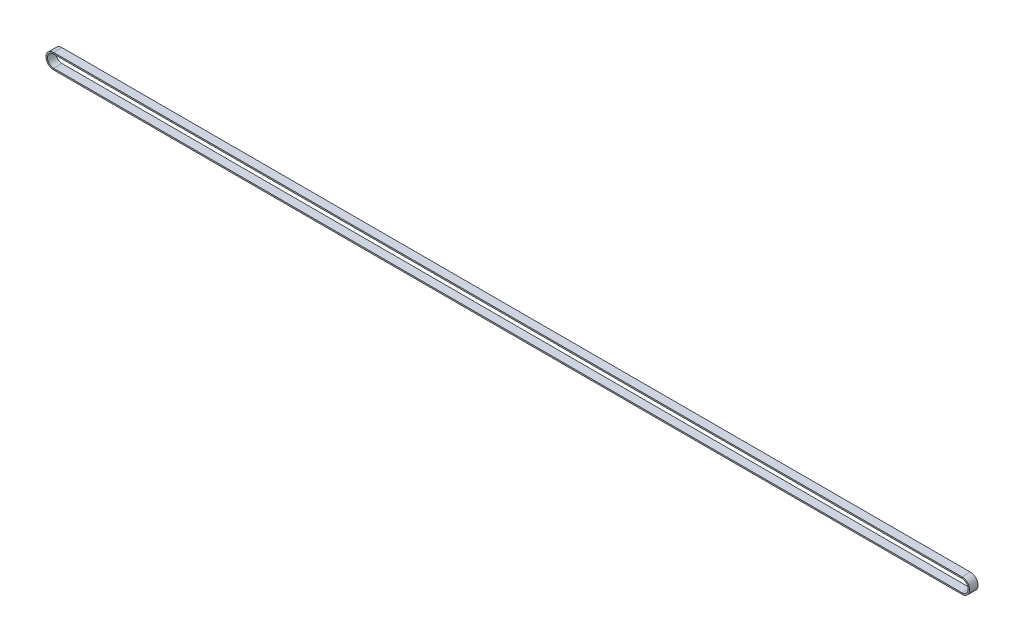
from build123d import *

# Parameters (mm, degrees)
SKETCH3_W = 9
SKETCH3_H = 1.5


with BuildPart() as part:
    # Sweep1: sweep along a path in Sketch2
    with BuildLine(Plane.XY) as sweep1_path:
        Line((632.867575204, -1418.562636498), (-343.463325095, -1418.562636498))
        ThreePointArc((-343.463325095, -1418.562636498), (-351.603075095, -1410.422886498), (-343.463325095, -1402.283136498))
        Line((-343.463325095, -1402.283136498), (632.867575204, -1402.283136498))
        ThreePointArc((632.867575204, -1402.283136498), (641.007325204, -1410.422886498), (632.867575204, -1418.562636498))
    # Sketch3 → Sweep1 (sweep)
    with BuildSketch(Plane(origin=(632.867575204, -1402.283136498, 0), x_dir=(0, 0, -1), z_dir=(1, 0, 0))):
        with Locations((4.5, -0.75)):
            Rectangle(SKETCH3_W, SKETCH3_H)
    sweep(path=sweep1_path.line)


solid = part.part
